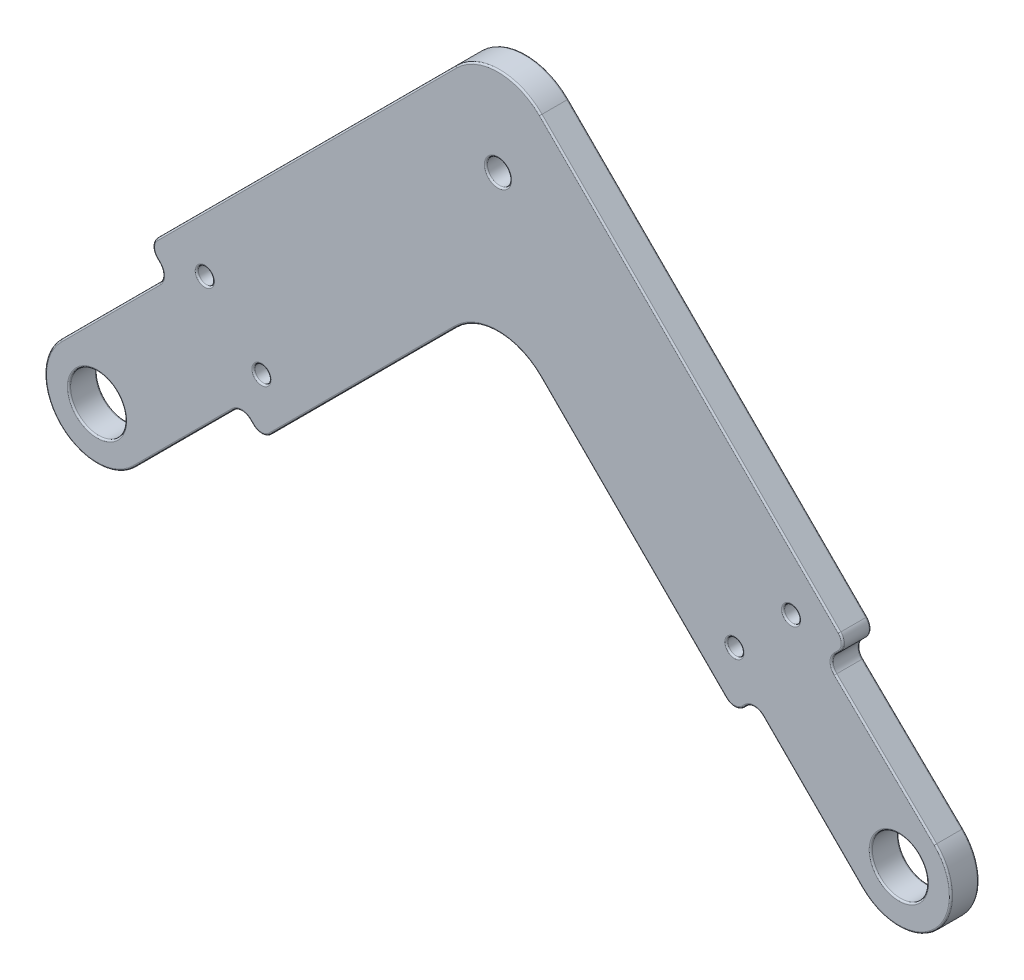
from build123d import *

# Parameters (mm, degrees)
SKETCH5_R           = 3.5
SKETCH5_R_2         = 1
SKETCH5_R_3         = 1.5
BOSS_EXTRUDE1_DEPTH = 3.5
FILLET1_R           = 7.5
FILLET2_R           = 1.5
FILLET3_R           = 0.2


with BuildPart() as part:
    # Sketch5 → Boss-Extrude1 (new body)
    with BuildSketch(Plane.XY):
        with BuildLine():
            Line((4.533955357, 4.657601188), (-9.019148409, 17.850909276))
            Line((-9.019148409, 17.850909276), (-6.363961031, 20.506096654))
            Line((-6.363961031, 20.506096654), (-50, 64.142135624))
            Line((-50, 64.142135624), (-93.636038969, 20.506096654))
            Line((-93.636038969, 20.506096654), (-91.161165235, 18.03122292))
            Line((-91.161165235, 18.03122292), (-104.596194078, 4.596194078))
            ThreePointArc((-104.596194078, 4.596194078), (-104.596194078, -4.596194078), (-95.403805922, -4.596194078))
            Line((-95.403805922, -4.596194078), (-81.96877708, 8.838834765))
            Line((-81.96877708, 8.838834765), (-79.493903346, 6.363961031))
            Line((-79.493903346, 6.363961031), (-50, 35.857864376))
            Line((-50, 35.857864376), (-20.506096654, 6.363961031))
            Line((-20.506096654, 6.363961031), (-18.03122292, 8.838834765))
            Line((-18.03122292, 8.838834765), (-4.596194078, -4.596194078))
            ThreePointArc((-4.596194078, -4.596194078), (4.627002282, -4.565177968), (4.533955357, 4.657601188))
        make_face()
        Circle(SKETCH5_R, mode=Mode.SUBTRACT)
        with Locations((-100, 0)):
            Circle(SKETCH5_R, mode=Mode.SUBTRACT)
        with Locations((-13.435028843, 20.506096654)):
            Circle(SKETCH5_R_2, mode=Mode.SUBTRACT)
        with Locations((-20.506096654, 13.435028843)):
            Circle(SKETCH5_R_2, mode=Mode.SUBTRACT)
        with Locations((-79.493903346, 13.435028843)):
            Circle(SKETCH5_R_2, mode=Mode.SUBTRACT)
        with Locations((-86.564971157, 20.506096654)):
            Circle(SKETCH5_R_2, mode=Mode.SUBTRACT)
        with Locations((-50, 50)):
            Circle(SKETCH5_R_3, mode=Mode.SUBTRACT)
    extrude(amount=-BOSS_EXTRUDE1_DEPTH)

    # Fillet1
    fillet1_edges = [part.edges().sort_by_distance(p)[0] for p in [
        (-50, 64.142135624, -1.75),
        (-50, 35.857864376, -1.75),
    ]]
    fillet(fillet1_edges, radius=FILLET1_R)

    # Fillet2
    fillet2_edges = [part.edges().sort_by_distance(p)[0] for p in [
        (-81.96877708, 8.838834765, -1.75),
        (-91.161165235, 18.03122292, -1.75),
        (-93.636038969, 20.506096654, -1.75),
        (-6.363961031, 20.506096654, -1.75),
        (-9.019148409, 17.850909276, -1.75),
        (-18.03122292, 8.838834765, -1.75),
        (-20.506096654, 6.363961031, -1.75),
        (-79.493903346, 6.363961031, -1.75),
    ]]
    fillet(fillet2_edges, radius=FILLET2_R)

    # Fillet3
    fillet3_edges = [part.edges().sort_by_distance(p)[0] for p in [
        (-91.782485579, 18.03122292, 0),
        (-91.782485579, 18.03122292, -3.5),
        (-81.96877708, 8.217514421, 0),
        (-81.96877708, 8.217514421, -3.5),
        (-18.03122292, 8.217514421, 0),
        (-18.03122292, 8.217514421, -3.5),
        (-8.383430059, 17.855184959, 0),
        (-8.383430059, 17.855184959, -3.5),
        (-89.216621587, 1.590990258, 0),
        (-104.596194078, -4.596194078, 0),
        (-1.697903009, 10.724021751, 0),
        (4.627002282, -4.565177968, 0),
        (4.627002282, -4.565177968, -3.5),
        (-1.697903009, 10.724021751, -3.5),
        (-3.5, 0, -3.5),
        (-3.5, 0, 0),
        (-103.5, 0, -3.5),
        (-103.5, 0, 0),
        (-104.596194078, -4.596194078, -3.5),
        (-14.435028843, 20.506096654, -3.5),
        (-14.435028843, 20.506096654, 0),
        (-89.216621587, 1.590990258, -3.5),
        (-21.506096654, 13.435028843, -3.5),
        (-21.506096654, 13.435028843, 0),
        (-80.493903346, 13.435028843, -3.5),
        (-80.493903346, 13.435028843, 0),
        (-87.564971157, 20.506096654, -3.5),
        (-87.564971157, 20.506096654, 0),
        (-51.5, 50, -3.5),
        (-51.5, 50, 0),
        (-33.131727984, 18.98959236, 0),
        (-73.939339828, 40.202795796, 0),
        (-50, 61.035533906, 0),
        (-73.939339828, 40.202795796, -3.5),
        (-33.131727984, 18.98959236, -3.5),
        (-50, 61.035533906, -3.5),
        (-50, 32.751262658, 0),
        (-50, 32.751262658, -3.5),
        (-26.060660172, 40.202795796, 0),
        (-92.398602102, 19.268659787, 0),
        (-98.409009742, 10.783378413, 0),
        (-80.731340213, 7.601397898, 0),
        (-66.868272016, 18.98959236, 0),
        (-19.268659787, 7.601397898, 0),
        (-10.783378413, 1.590990258, 0),
        (-7.684372679, 19.185685006, 0),
        (-6.985281374, 20.506096654, 0),
        (-20.506096654, 6.985281374, 0),
        (-79.493903346, 6.985281374, 0),
        (-93.014718626, 20.506096654, 0),
        (-92.398602102, 19.268659787, -3.5),
        (-26.060660172, 40.202795796, -3.5),
        (-7.684372679, 19.185685006, -3.5),
        (-10.783378413, 1.590990258, -3.5),
        (-19.268659787, 7.601397898, -3.5),
        (-66.868272016, 18.98959236, -3.5),
        (-80.731340213, 7.601397898, -3.5),
        (-98.409009742, 10.783378413, -3.5),
        (-6.985281374, 20.506096654, -3.5),
        (-20.506096654, 6.985281374, -3.5),
        (-79.493903346, 6.985281374, -3.5),
        (-93.014718626, 20.506096654, -3.5),
    ]]
    fillet(fillet3_edges, radius=FILLET3_R)


solid = part.part
